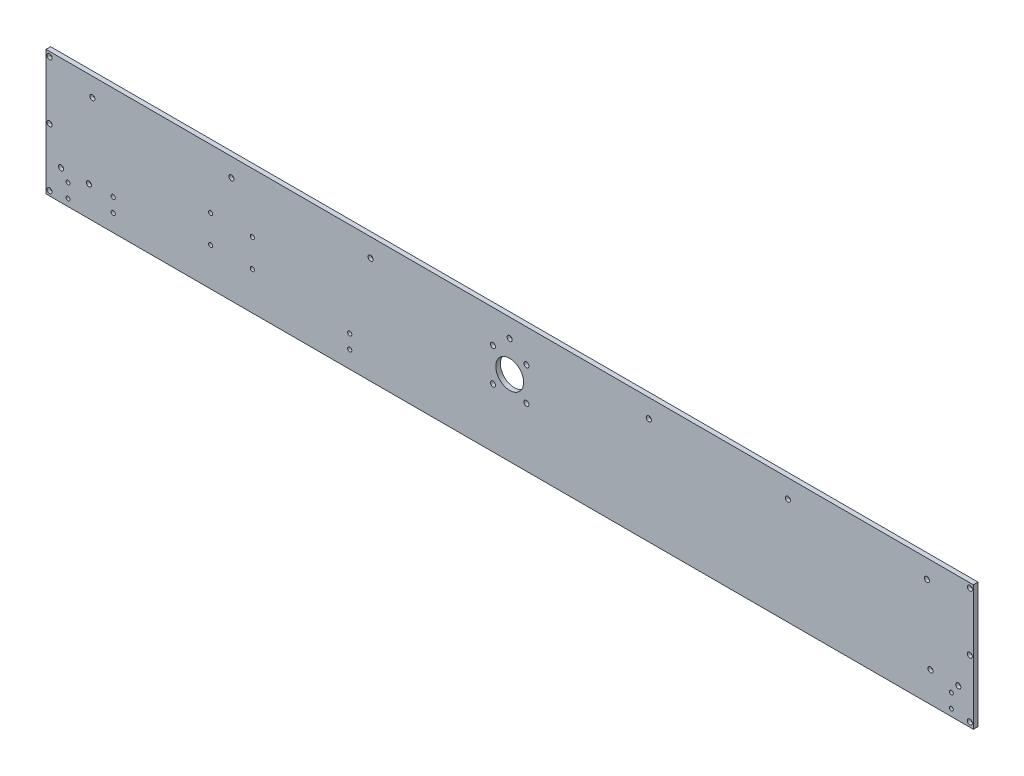
from build123d import *

# Parameters (mm, degrees)
SKETCH_1_W                = 2000
SKETCH_1_H                = 270
EXTRUDE_1_DEPTH           = 5
HOLE_WIZARD_1_D           = 6.6
HOLE_WIZARD_1_CBORE_D     = 11
HOLE_WIZARD_1_CBORE_DEPTH = 6.8
HOLE_WIZARD_M10_1_D       = 8.5
HOLE_WIZARD_9_0_9_3_D     = 9
HOLE_WIZARD_9_0_9_4_D     = 9
HOLE_WIZARD_11_0_11_1_D   = 11
SKETCH_20_R               = 30
CUT_EXTRUDE_1_DEPTH       = 11
HOLE_WIZARD_5_D           = 6.6
HOLE_WIZARD_5_CBORE_D     = 11
HOLE_WIZARD_5_CBORE_DEPTH = 6.8
HOLE_WIZARD_6_D           = 6.6
HOLE_WIZARD_6_CBORE_D     = 11
HOLE_WIZARD_6_CBORE_DEPTH = 6.8


with BuildPart() as part:
    # 草图1 → 凸台-拉伸1 (new body, symmetric)
    with BuildSketch(Plane.XY):
        Rectangle(SKETCH_1_W, SKETCH_1_H)
    extrude(amount=EXTRUDE_1_DEPTH, both=True)

    # 打孔尺寸(%根据)内六角圆柱头螺钉的类型1 (through all)
    with Locations(Plane(origin=(-992.5, 125, 5), x_dir=(1, 0, 0), z_dir=(0, 0, 1))):
        with Locations((0, 0), (0, -250), (1985, 0), (1985, -250), (1985, -125), (0, -125)):
            CounterBoreHole(HOLE_WIZARD_1_D / 2, HOLE_WIZARD_1_CBORE_D / 2, HOLE_WIZARD_1_CBORE_DEPTH)

    # M10 螺纹孔1 (through all)
    with Locations(Plane(origin=(952.5, -120, 5), x_dir=(1, 0, 0), z_dir=(0, 0, 1))):
        with Locations((0, 0), (0, 30)):
            hole_wizard_m10_1 = Hole(HOLE_WIZARD_M10_1_D / 2)

    # Ø9.0 (9) 直径孔3 (through all)
    with Locations(Plane(origin=(-345, -68, -5), x_dir=(-1, 0, 0), z_dir=(0, 0, -1))):
        with Locations((0, 0), (0, -30), (510, 0), (510, -30)):
            Hole(HOLE_WIZARD_9_0_9_3_D / 2)

    # Ø9.0 (9) 直径孔4 (through all)
    with Locations(Plane(origin=(-555, 7, -5), x_dir=(-1, 0, 0), z_dir=(0, 0, -1))):
        with Locations((0, 0), (90, 0), (90, -60), (0, -60)):
            Hole(HOLE_WIZARD_9_0_9_4_D / 2)

    # Ø11.0 (11) 直径孔1 (through all)
    with Locations(Plane(origin=(36, -8, -5), x_dir=(-1, 0, 0), z_dir=(0, 0, -1))):
        with Locations((0, 0), (72, 0), (72, 72), (0, 72)):
            Hole(HOLE_WIZARD_11_0_11_1_D / 2)

    # 草图20 → 切除-拉伸1 (cut, through all)
    with BuildSketch(Plane(origin=(0, 0, -5), x_dir=(-1, 0, 0), z_dir=(0, 0, -1))):
        with Locations((0, 28)):
            Circle(SKETCH_20_R)
    extrude(amount=-CUT_EXTRUDE_1_DEPTH, mode=Mode.SUBTRACT)

    # 打孔尺寸(%根据)内六角圆柱头螺钉的类型5 (through all)
    with Locations(Plane(origin=(-900, 95, 5), x_dir=(1, 0, 0), z_dir=(0, 0, 1))):
        with Locations((0, 0), (300, 0), (600, 0), (900, 0), (1200, 0), (1500, 0), (1800, 0)):
            CounterBoreHole(HOLE_WIZARD_5_D / 2, HOLE_WIZARD_5_CBORE_D / 2, HOLE_WIZARD_5_CBORE_DEPTH)

    # 镜向1: M10 螺纹孔1 across plane
    add(hole_wizard_m10_1.mirror(Plane(origin=(0, 0, 0), x_dir=(0, 0, 1), z_dir=(1, 0, 0))), mode=Mode.SUBTRACT)

    # 打孔尺寸(%根据)内六角圆柱头螺钉的类型6 (through all)
    with Locations(Plane(origin=(907.5, -70, 5), x_dir=(1, 0, 0), z_dir=(0, 0, 1))):
        with Locations((0, 0), (60, 0)):
            hole_wizard_6 = CounterBoreHole(HOLE_WIZARD_6_D / 2, HOLE_WIZARD_6_CBORE_D / 2, HOLE_WIZARD_6_CBORE_DEPTH)

    # 镜向2: 打孔尺寸(%根据)内六角圆柱头螺钉的类型6 across plane
    add(hole_wizard_6.mirror(Plane(origin=(0, 0, 0), x_dir=(0, 0, 1), z_dir=(1, 0, 0))), mode=Mode.SUBTRACT)


solid = part.part
